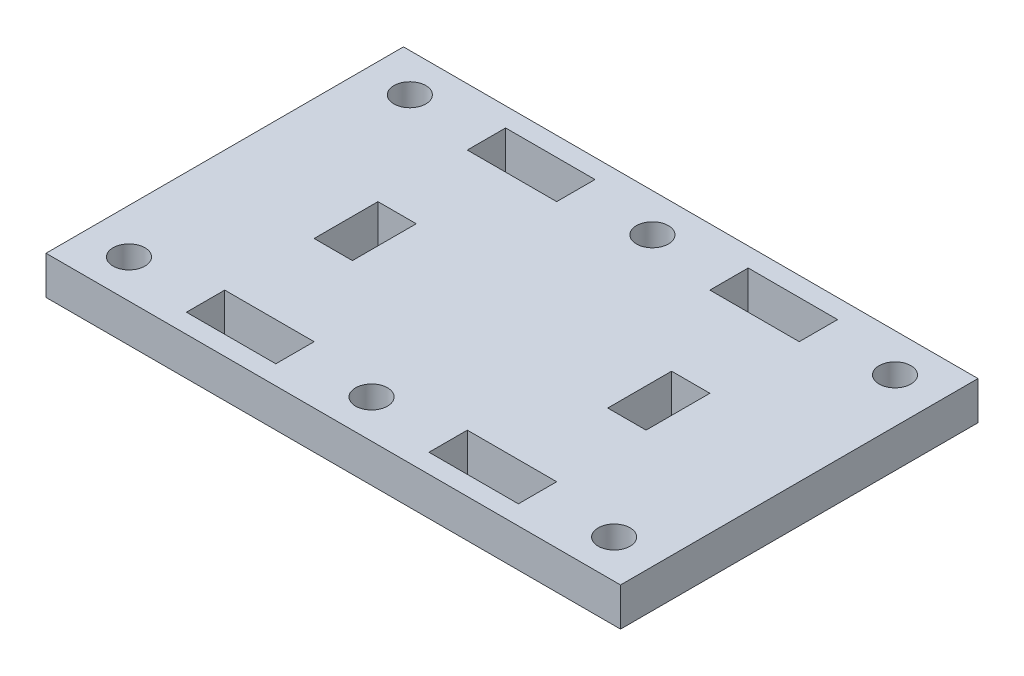
from build123d import *

# Parameters (mm, degrees)
SKETCH_1_W          = 45
SKETCH_1_H          = 28
EXTRUDE_1_DEPTH     = 3
SKETCH_2_R          = 1.25
SKETCH_2_W          = 7
SKETCH_2_H          = 3
CUT_EXTRUDE_1_DEPTH = 4
SKETCH_3_W          = 3
SKETCH_3_H          = 5
CUT_EXTRUDE_2_DEPTH = 4


with BuildPart() as part:
    # 스케치1 → 보스-돌출1 (new body)
    with BuildSketch(Plane(origin=(0, 0, 0), x_dir=(1, 0, 0), z_dir=(0, 1, 0))):
        with Locations((22.5, 14)):
            Rectangle(SKETCH_1_W, SKETCH_1_H)
    extrude(amount=EXTRUDE_1_DEPTH)

    # 스케치2 → 컷-돌출1 (cut, through all)
    with BuildSketch(Plane(origin=(0, 3, 0), x_dir=(1, 0, 0), z_dir=(0, 1, 0))):
        with Locations((22.5, 3)):
            Circle(SKETCH_2_R)
        with Locations((22.5, 25)):
            Circle(SKETCH_2_R)
        with Locations((3.5, 3)):
            Circle(SKETCH_2_R)
        with Locations((41.5, 3)):
            Circle(SKETCH_2_R)
        with Locations((41.5, 25)):
            Circle(SKETCH_2_R)
        with Locations((3.5, 25)):
            Circle(SKETCH_2_R)
        with Locations((32, 3)):
            Rectangle(SKETCH_2_W, SKETCH_2_H)
        with Locations((13, 3)):
            Rectangle(SKETCH_2_W, SKETCH_2_H)
        with Locations((32, 25)):
            Rectangle(SKETCH_2_W, SKETCH_2_H)
        with Locations((13, 25)):
            Rectangle(SKETCH_2_W, SKETCH_2_H)
    extrude(amount=-CUT_EXTRUDE_1_DEPTH, mode=Mode.SUBTRACT)

    # 스케치3 → 컷-돌출2 (cut, through all)
    with BuildSketch(Plane(origin=(0, 3, 0), x_dir=(1, 0, 0), z_dir=(0, 1, 0))):
        with Locations((11, 14)):
            Rectangle(SKETCH_3_W, SKETCH_3_H)
        with Locations((34, 14)):
            Rectangle(SKETCH_3_W, SKETCH_3_H)
    extrude(amount=-CUT_EXTRUDE_2_DEPTH, mode=Mode.SUBTRACT)


solid = part.part
